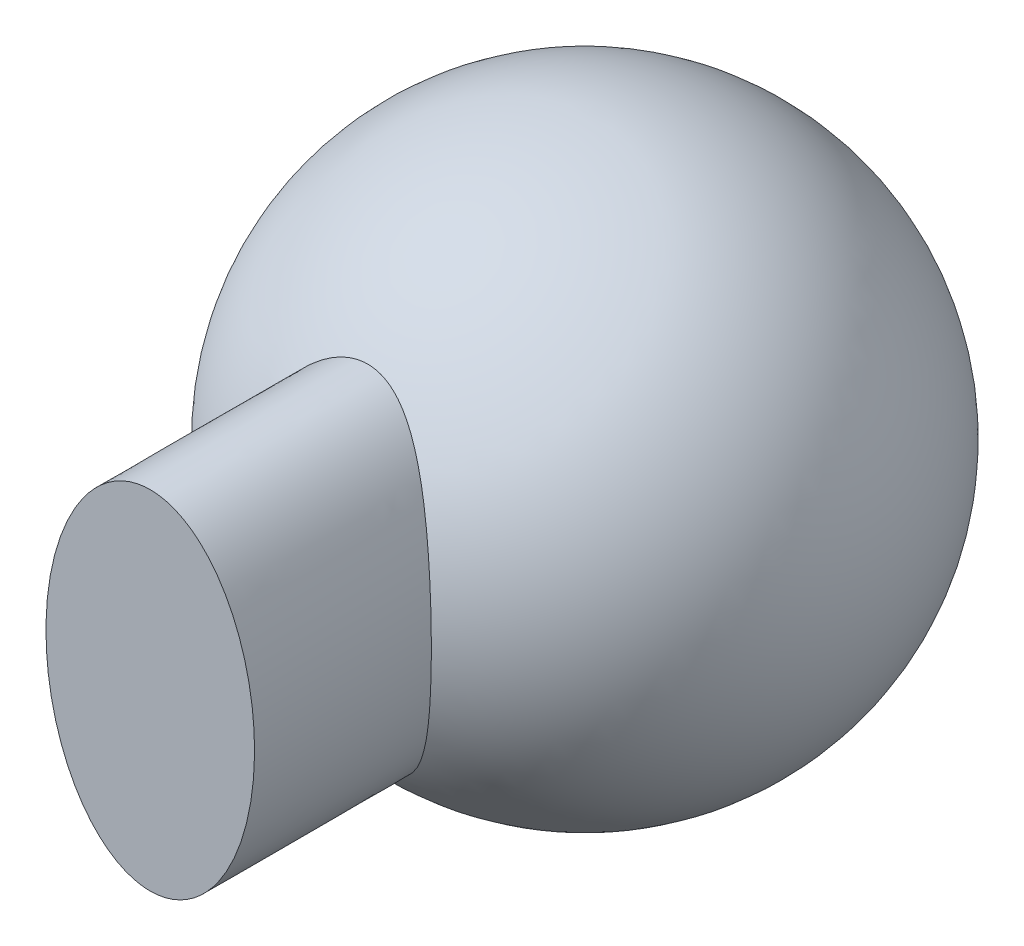
from build123d import *

# Parameters (mm, degrees)
SKETCH3_RX          = 7.9375
SKETCH3_RY          = 4.7625
BOSS_EXTRUDE1_DEPTH = 19.84375


with BuildPart() as part:
    # Sketch1 → Revolve1 (revolve)
    with BuildSketch(Plane.XY):
        with BuildLine():
            Line((0, 12.7), (0, -12.7))
            ThreePointArc((0, -12.7), (-12.7, 0), (0, 12.7))
        make_face()
    revolve(axis=Axis((0, 12.7, 0), (0, -1, 0)))

    # Sketch3 → Boss-Extrude1 (add)
    with BuildSketch(Plane.XY):
        with Locations(Location((0, 0), (0, 0, -90))):
            Ellipse(SKETCH3_RX, SKETCH3_RY)
    extrude(amount=BOSS_EXTRUDE1_DEPTH)


solid = part.part
